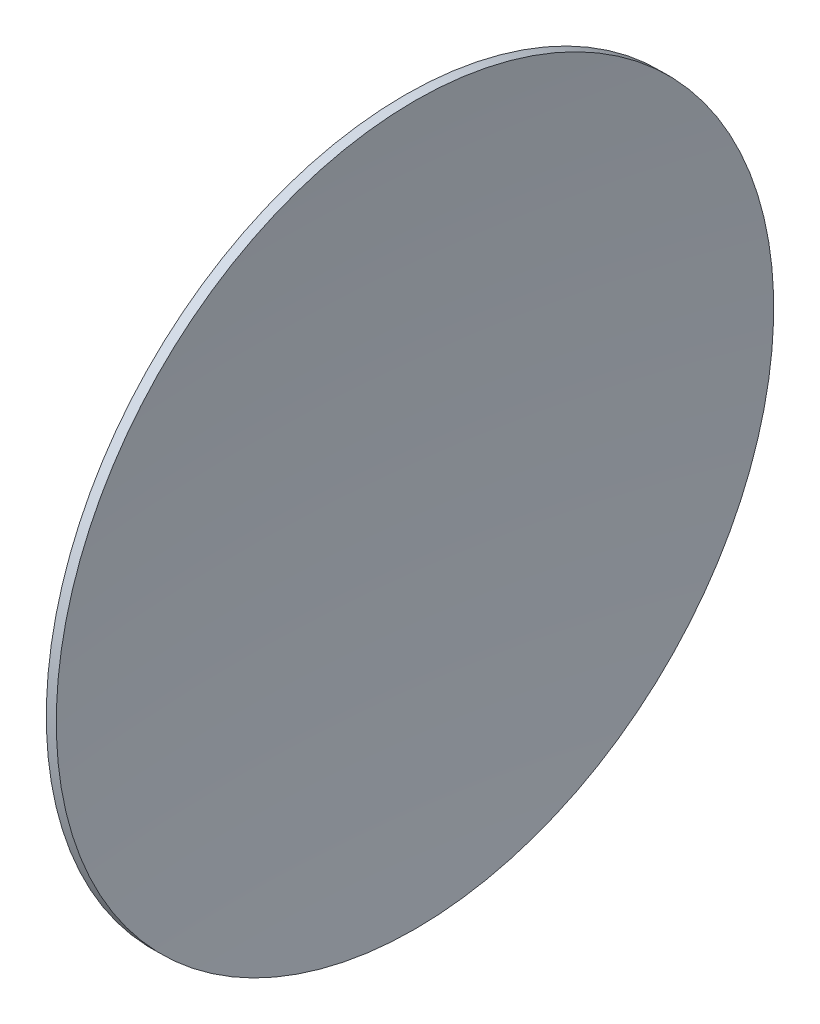
from build123d import *


with BuildPart() as part:
    # Sketch1 → Revolve1 (revolve)
    with BuildSketch(Plane.XY):
        with BuildLine():
            Line((-16.995417101, 23.232569393), (-17.497888078, 23.232569393))
            ThreePointArc((-17.497888078, 23.232569393), (-18.168836589, 14.219901307), (-18.392669156, 5.185065564))
            Line((-18.392669156, 5.185065564), (-17.892669156, 5.185065564))
            ThreePointArc((-17.892669156, 5.185065564), (-17.668217705, 14.219962571), (-16.995417101, 23.232569393))
        make_face()
    revolve(axis=Axis((-14.495417101, 5.185065564, 0), (-1, 0, 0)))


solid = part.part
